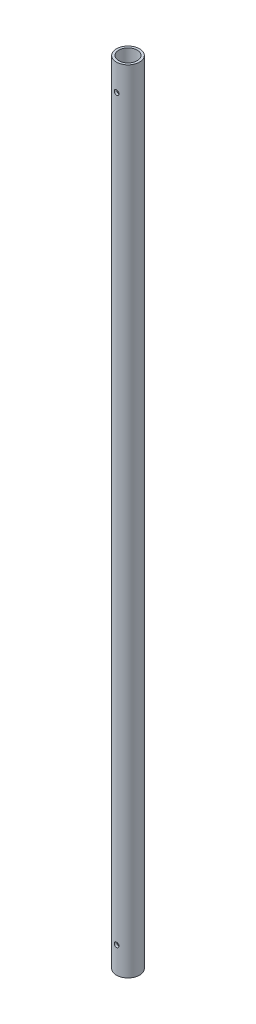
from build123d import *

# Parameters (mm, degrees)
SKETCH1_R               = 16.7005
BOSS_EXTRUDE1_DEPTH     = 1143
CUT_EXTRUDE1_DEPTH      = 25.4
CUT_EXTRUDE1_DEPTH_BACK = 25.4
SKETCH2_R               = 3.429
SKETCH3_R               = 13.3223
CUT_EXTRUDE2_DEPTH      = 1144.243986923


with BuildPart() as part:
    # Sketch1 → Boss-Extrude1 (new body)
    with BuildSketch(Plane(origin=(0, 0, 0), x_dir=(1, 0, 0), z_dir=(0, 1, 0))):
        Circle(SKETCH1_R)
    extrude(amount=BOSS_EXTRUDE1_DEPTH)

    # Sketch2 → Cut-Extrude1 (cut, two sides: drawn at the far end of the back side and taken through both)
    with BuildSketch(Plane.XY.offset(-CUT_EXTRUDE1_DEPTH_BACK)):
        with Locations((0, 38.1)):
            Circle(SKETCH2_R)
        with Locations((0, 1104.9)):
            Circle(SKETCH2_R)
    extrude(amount=CUT_EXTRUDE1_DEPTH + CUT_EXTRUDE1_DEPTH_BACK, mode=Mode.SUBTRACT)

    # Sketch3 → Cut-Extrude2 (cut, through all)
    with BuildSketch(Plane.XZ):
        Circle(SKETCH3_R)
    extrude(amount=-CUT_EXTRUDE2_DEPTH, mode=Mode.SUBTRACT)


solid = part.part
